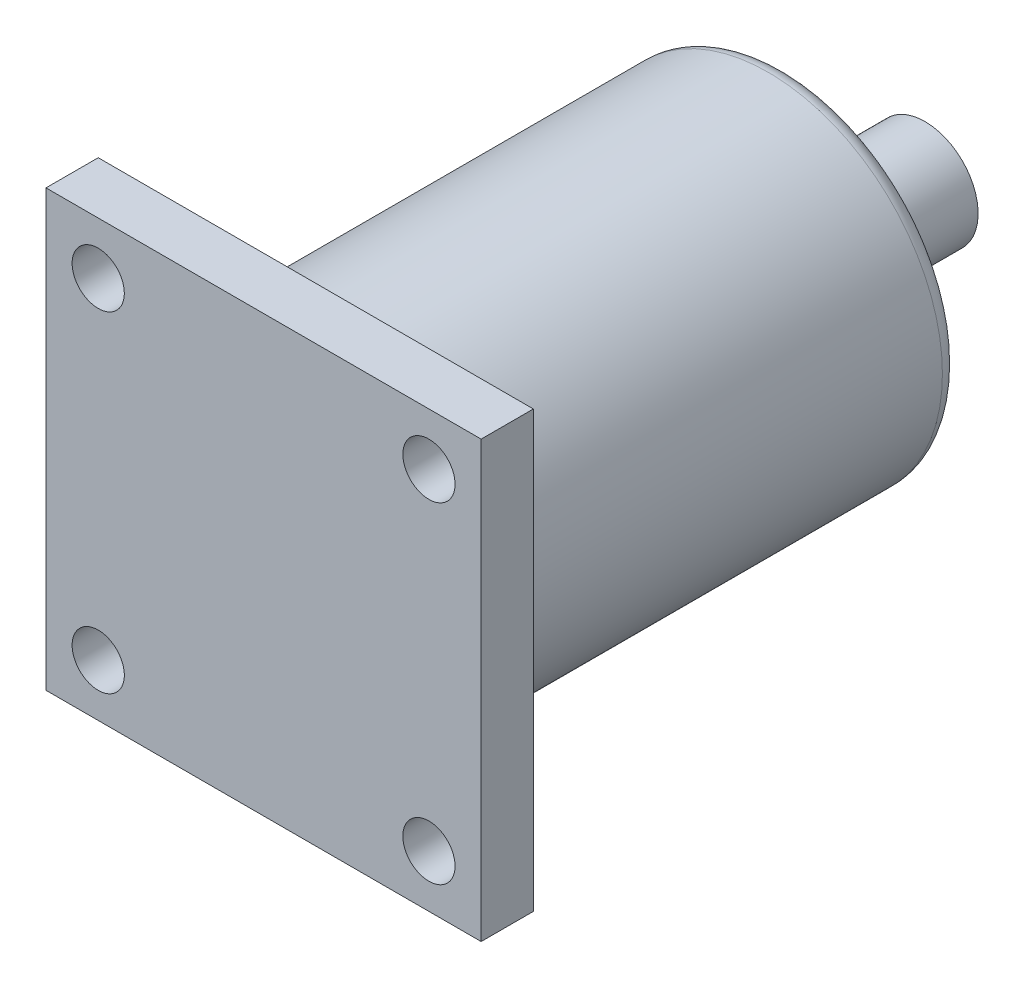
from build123d import *

# Parameters (mm, degrees)
SKETCH_2_W          = 25
SKETCH_2_H          = 25
EXTRUDE_1_DEPTH     = 3
SKETCH_3_R          = 1.5
CUT_EXTRUDE_2_DEPTH = 4
EXTRUDE_START       = -3
SKETCH_4_R          = 10
EXTRUDE_2_DEPTH     = 27
SKETCH_5_R          = 3.05
EXTRUDE_3_DEPTH     = 8
FILLET_3_R          = 1


with BuildPart() as part:
    # 草图2 → 凸台-拉伸1 (new body)
    with BuildSketch(Plane.XY):
        with Locations((12.5, -12.5)):
            Rectangle(SKETCH_2_W, SKETCH_2_H)
    extrude(amount=EXTRUDE_1_DEPTH)

    # 草图3 → 切除-拉伸2 (cut, through all)
    with BuildSketch(Plane(origin=(0, 0, 0), x_dir=(-1, 0, 0), z_dir=(0, 0, -1))):
        with Locations((-22, -3)):
            Circle(SKETCH_3_R)
        with Locations((-3, -3)):
            Circle(SKETCH_3_R)
        with Locations((-3, -22)):
            Circle(SKETCH_3_R)
        with Locations((-22, -22)):
            Circle(SKETCH_3_R)
    extrude(amount=-CUT_EXTRUDE_2_DEPTH, mode=Mode.SUBTRACT)

    # 草图4 → 凸台-拉伸2 (add)
    with BuildSketch(Plane.XY.offset(3).offset(EXTRUDE_START)):
        with Locations((12.5, -12.5)):
            Circle(SKETCH_4_R)
    extrude(amount=-EXTRUDE_2_DEPTH)

    # 草图5 → 凸台-拉伸3 (add)
    with BuildSketch(Plane(origin=(0, 0, -27), x_dir=(-1, 0, 0), z_dir=(0, 0, -1))):
        with Locations((-12.5, -12.5)):
            Circle(SKETCH_5_R)
    extrude(amount=EXTRUDE_3_DEPTH)

    # 圆角3
    fillet_3_edges = [part.edges().sort_by_distance(p)[0] for p in [
        (2.5, -12.5, -27),
        (2.5, -12.5, 0),
    ]]
    fillet(fillet_3_edges, radius=FILLET_3_R)


solid = part.part
